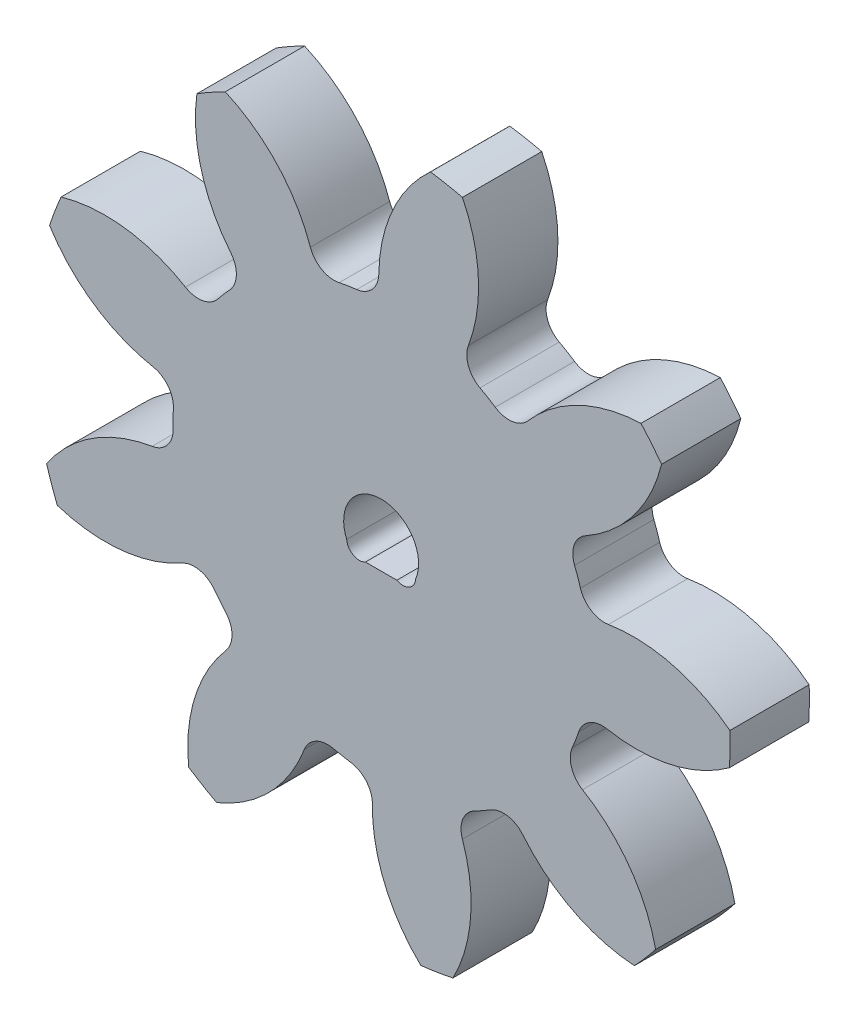
from build123d import *

# Parameters (mm, degrees)
SKETCH3_R           = 13.97
GEARBODY_DEPTH      = 3.175
TOOTHCUT_DEPTH      = 4.175
CIRPATTERN1_COUNT   = 9
BOREDIA_R           = 1.499997014
BORE_DEPTH          = 12700
BOSS_EXTRUDE1_DEPTH = 3.175
SKETCH5_R           = 0.508
CUT_EXTRUDE1_DEPTH  = 4.175


with BuildPart() as part:
    # Sketch3 → gearBody (new body)
    with BuildSketch(Plane.XY):
        Circle(SKETCH3_R)
    extrude(amount=GEARBODY_DEPTH)

    # Sketch2 → toothCut (cut, through all)
    with BuildSketch(Plane.XY):
        with BuildLine():
            ThreePointArc((7.654596591, -3.288775527), (7.788168987, -2.958600559), (7.907507119, -2.623018223))
            ThreePointArc((7.907507119, -2.623018223), (8.3519289, -2.073263372), (9.048439358, -1.952373766))
            ThreePointArc((9.048439358, -1.952373766), (13.146424788, -1.34364254), (15.979509974, 1.679214819))
            ThreePointArc((15.979509974, 1.679214819), (15.020212204, -5.705937852), (10.834165744, -11.865300419))
            ThreePointArc((10.834165744, -11.865300419), (10.7226862, -7.723850118), (8.062481966, -4.547790968))
            ThreePointArc((8.062481966, -4.547790968), (7.621913496, -3.994943305), (7.654596591, -3.288775527))
        make_face()
    toothcut = extrude(amount=TOOTHCUT_DEPTH, mode=Mode.SUBTRACT)

    # CirPattern1: toothCut ×9 about axis
    cirpattern1_axis = Axis((0, 0, 0), (0, 0, 1))
    for i in range(1, CIRPATTERN1_COUNT):
        add(toothcut.rotate(cirpattern1_axis, i * 360 / CIRPATTERN1_COUNT), mode=Mode.SUBTRACT)

    # boreDia → bore (cut, symmetric)
    with BuildSketch(Plane.XY):
        Circle(BOREDIA_R)
    extrude(amount=BORE_DEPTH, both=True, mode=Mode.SUBTRACT)

    # Sketch4 → Boss-Extrude1 (add)
    with BuildSketch(Plane(origin=(0, 0, 0), x_dir=(-1, 0, 0), z_dir=(0, 0, -1))):
        with BuildLine():
            Line((1.118029954, -1.000000032), (-1.118029954, -1.000000032))
            ThreePointArc((-1.118029954, -1.000000032), (0, -1.499997014), (1.118029954, -1.000000032))
        make_face()
    extrude(amount=-BOSS_EXTRUDE1_DEPTH)

    # Sketch5 → Cut-Extrude1 (cut, through all)
    with BuildSketch(Plane.XY.offset(3.175)):
        with Locations((-0.873392334, -0.554784988)):
            Circle(SKETCH5_R)
        with Locations((0.873392334, -0.554784988)):
            Circle(SKETCH5_R)
    extrude(amount=-CUT_EXTRUDE1_DEPTH, mode=Mode.SUBTRACT)


solid = part.part
